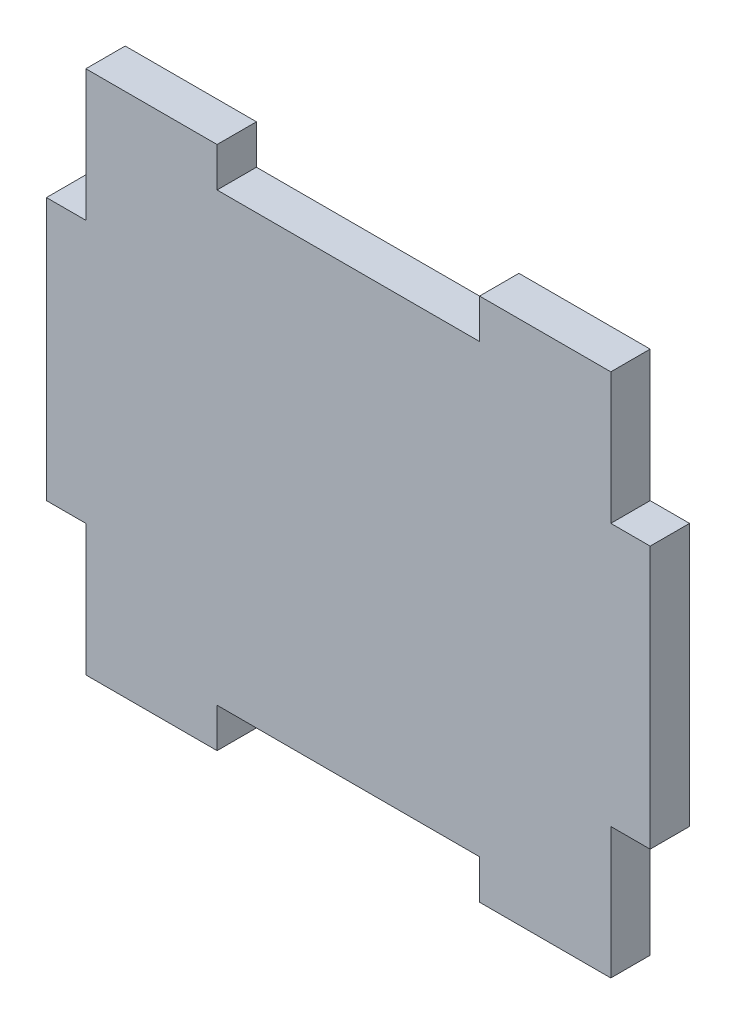
from build123d import *

# Parameters (mm, degrees)
SALIENTE_EXTRUIR1_DEPTH = 3
CROQUIS6_W              = 20
CROQUIS6_H              = 3
CORTAR_EXTRUIR2_DEPTH   = 3


with BuildPart() as part:
    # Croquis1 → Saliente-Extruir1 (new body)
    with BuildSketch(Plane.XY):
        Polygon((-18.90011512, 20.848965056), (21.09988488, 20.848965056), (21.09988488, 10.848965056), (24.09988488, 10.848965056), (24.09988488, -9.151034944), (21.09988488, -9.151034944), (21.09988488, -19.151034944), (-18.90011512, -19.151034944), (-18.90011512, -9.151034944), (-21.90011512, -9.151034944), (-21.90011512, 10.848965056), (-18.90011512, 10.848965056), align=None)
    extrude(amount=SALIENTE_EXTRUIR1_DEPTH)

    # Croquis6 → Cortar-Extruir2 (cut)
    with BuildSketch(Plane.XY.offset(3)):
        with Locations((1.09988488, 19.348965056)):
            Rectangle(CROQUIS6_W, CROQUIS6_H)
        with Locations((1.09988488, -17.651034944)):
            Rectangle(CROQUIS6_W, CROQUIS6_H)
    extrude(amount=-CORTAR_EXTRUIR2_DEPTH, mode=Mode.SUBTRACT)


solid = part.part
